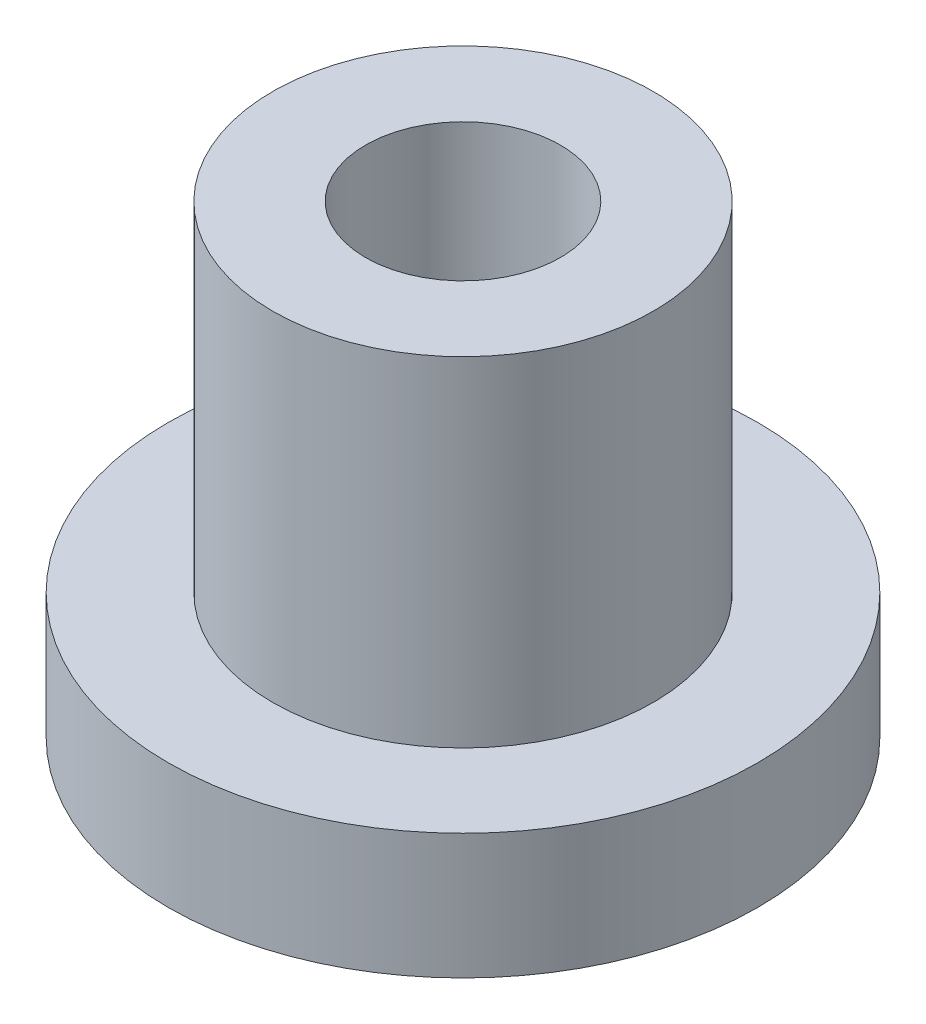
from build123d import *

# Parameters (mm, degrees)
SKETCH1_R               = 6.35
BASE_BODY_DEPTH         = 10
SKETCH2_R               = 2.1
SHAFT_BEARING_CUT_DEPTH = 11
SKETCH3_OUTSIDE_W       = 18.812
SKETCH3_OUTSIDE_H       = 18.812
SKETCH3_OUTSIDE_R       = 4.1
LATHE_CUT_DEPTH         = 7.3


with BuildPart() as part:
    # Sketch1 → base_body (new body)
    with BuildSketch(Plane(origin=(0, 0, 0), x_dir=(1, 0, 0), z_dir=(0, 1, 0))):
        Circle(SKETCH1_R)
    extrude(amount=BASE_BODY_DEPTH)

    # Sketch2 → shaft_bearing_cut (cut, through all)
    with BuildSketch(Plane(origin=(0, 10, 0), x_dir=(1, 0, 0), z_dir=(0, 1, 0))):
        Circle(SKETCH2_R)
    extrude(amount=-SHAFT_BEARING_CUT_DEPTH, mode=Mode.SUBTRACT)

    # Sketch3 outside → lathe_cut (cut)
    with BuildSketch(Plane(origin=(0, 10, 0), x_dir=(1, 0, 0), z_dir=(0, 1, 0))):
        Rectangle(SKETCH3_OUTSIDE_W, SKETCH3_OUTSIDE_H)
        Circle(SKETCH3_OUTSIDE_R, mode=Mode.SUBTRACT)
    extrude(amount=-LATHE_CUT_DEPTH, mode=Mode.SUBTRACT)


solid = part.part
